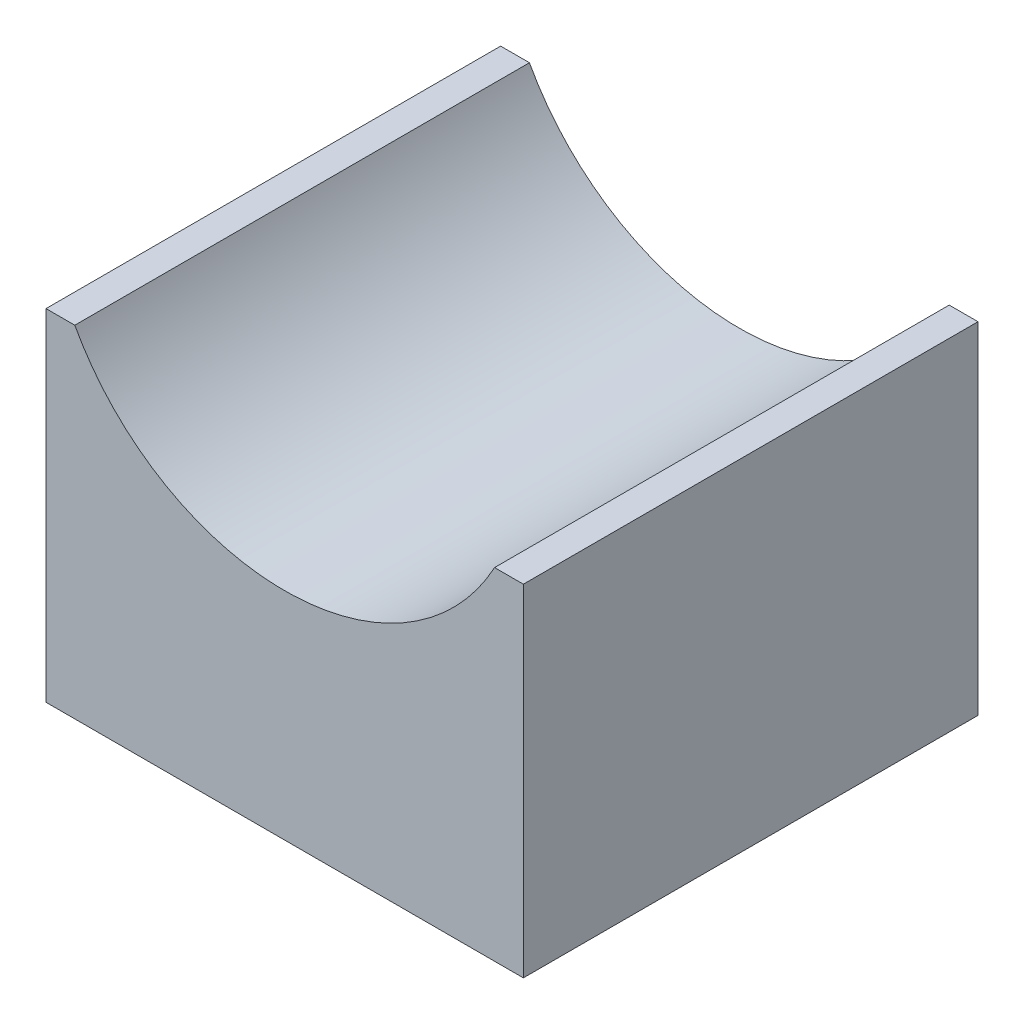
from build123d import *

# Parameters (mm, degrees)
EXTRUDE_1_DEPTH = 10


with BuildPart() as part:
    # 草图1 → 凸台-拉伸1 (new body, symmetric)
    with BuildSketch(Plane.XY):
        with BuildLine():
            Line((-10.5, 15), (-10.5, 0))
            Line((-10.5, 0), (10.5, 0))
            Line((10.5, 0), (10.5, 15))
            Line((10.5, 15), (9.233092656, 15))
            ThreePointArc((9.233092656, 15), (0, 9.5), (-9.233092656, 15))
            Line((-9.233092656, 15), (-10.5, 15))
        make_face()
    extrude(amount=EXTRUDE_1_DEPTH, both=True)


solid = part.part
